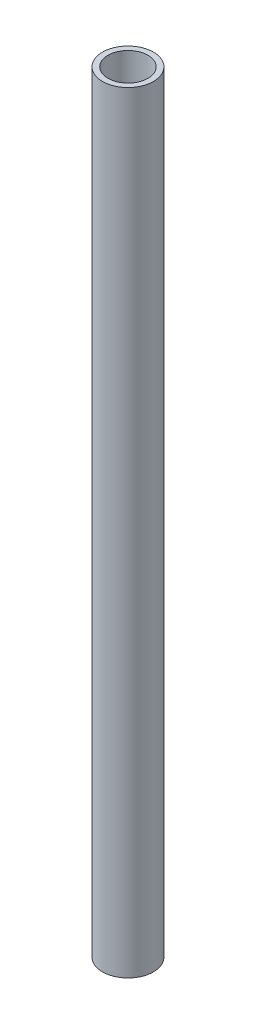
from build123d import *

# Parameters (mm, degrees)
SKETCH1_R           = 16.764
SKETCH1_R_2         = 13.17625
BOSS_EXTRUDE1_DEPTH = 508


with BuildPart() as part:
    # Sketch1 → Boss-Extrude1 (new body)
    with BuildSketch(Plane(origin=(0, 0, 0), x_dir=(1, 0, 0), z_dir=(0, 1, 0))):
        Circle(SKETCH1_R)
        Circle(SKETCH1_R_2, mode=Mode.SUBTRACT)
    extrude(amount=BOSS_EXTRUDE1_DEPTH)


solid = part.part
